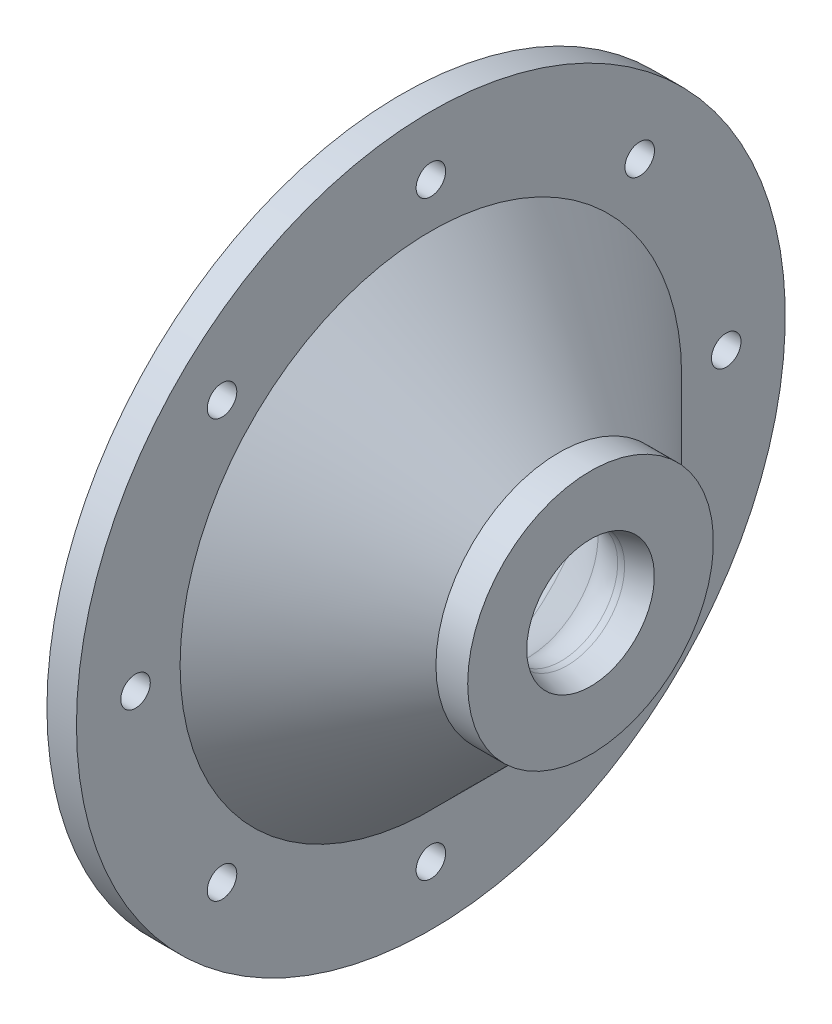
from build123d import *

# Parameters (mm, degrees)
F_1_8_0_125_DIAMETER_HOLE1_D = 3.175
CIRPATTERN1_COUNT            = 8


with BuildPart() as part:
    # Sketch1 → Revolve1 (revolve)
    with BuildSketch(Plane.XY):
        with BuildLine():
            Line((3.592102448, 17.562102448), (13.570307345, 7.583897552))
            ThreePointArc((13.570307345, 7.583897552), (15.218377957, 6.482691975), (17.162409794, 6.096))
            ThreePointArc((17.162409794, 6.096), (17.493946322, 6.117730052), (17.819810168, 6.182548401))
            Line((17.819810168, 6.182548401), (20.340629853, 6.858))
            Line((20.340629853, 6.858), (20.340629853, 13.208))
            Line((20.340629853, 13.208), (16.926461018, 13.208))
            Line((16.926461018, 13.208), (3.175, 26.959461018))
            Line((3.175, 26.959461018), (3.175, 38.1))
            Line((3.175, 38.1), (0, 38.1))
            Line((0, 38.1), (0, 19.05))
            ThreePointArc((0, 19.05), (1.944031836, 18.663308025), (3.592102448, 17.562102448))
        make_face()
    revolve(axis=Axis((0, 0, 0), (1, 0, 0)))

    # 1_8 _0.125_ Diameter Hole1 (through all)
    with Locations(Plane(origin=(3.175, 0, 0), x_dir=(0, 0, -1), z_dir=(1, 0, 0))):
        with Locations((0, 31.75)):
            f_1_8_0_125_diameter_hole1 = Hole(F_1_8_0_125_DIAMETER_HOLE1_D / 2)

    # CirPattern1: 1_8 _0.125_ Diameter Hole1 ×8 about axis
    cirpattern1_axis = Axis((-78.819685074, 0, 0), (1, 0, 0))
    for i in range(1, CIRPATTERN1_COUNT):
        add(f_1_8_0_125_diameter_hole1.rotate(cirpattern1_axis, i * 360 / CIRPATTERN1_COUNT), mode=Mode.SUBTRACT)


solid = part.part
